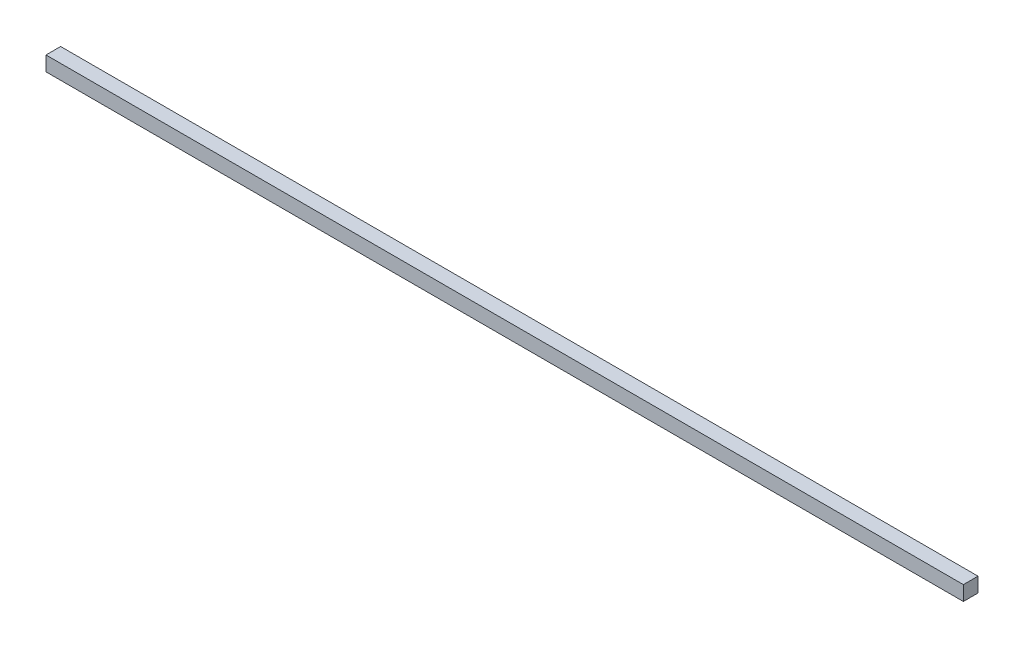
from build123d import *

# Parameters (mm, degrees)
SKETCH2_W           = 4.7625
SKETCH2_H           = 4.7625
BOSS_EXTRUDE1_DEPTH = 298.45


with BuildPart() as part:
    # Sketch2 → Boss-Extrude1 (new body)
    with BuildSketch(Plane(origin=(0, 0, 0), x_dir=(0, 0, -1), z_dir=(1, 0, 0))):
        with Locations((2.38125, 2.38125)):
            Rectangle(SKETCH2_W, SKETCH2_H)
    extrude(amount=-BOSS_EXTRUDE1_DEPTH)


solid = part.part
